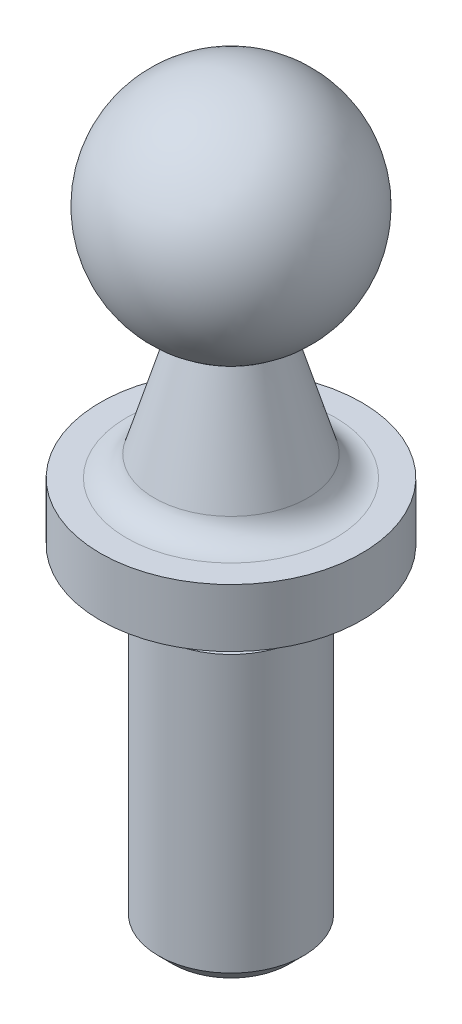
from build123d import *

# Parameters (mm, degrees)
CHANFREIN1_SIZE = 0.5
CONG_1_R        = 1


with BuildPart() as part:
    # Esquisse2 → Base-Révolution (revolve)
    with BuildSketch(Plane.XY, mode=Mode.PRIVATE) as base_r_volution_sk:
        with BuildLine():
            Line((1.5, -7.5), (2.85, -12))
            Line((2.85, -12), (4.5, -12))
            Line((4.5, -12), (4.5, -14))
            Line((4.5, -14), (2.5, -14))
            Line((2.5, -14), (2.002434927, -14))
            Line((2.002434927, -14), (2.002434927, -15.5))
            Line((2.002434927, -15.5), (2.5, -15.5))
            Line((2.5, -15.5), (2.5, -25.5))
            Line((2.5, -25.5), (0, -25.5))
            Line((0, -25.5), (0, 0))
            ThreePointArc((0, 0), (3.824264635, -3.135147073), (1.5, -7.5))
        make_face()
    revolve(base_r_volution_sk.sketch.rotate(Axis((0, 10.187617919, 0), (0, -1, 0)), 90), axis=Axis((0, 10.187617919, 0), (0, -1, 0)))  # turned: the seam where the file's is

    # Chanfrein1
    chanfrein1_edges = [part.edges().sort_by_distance(p)[0] for p in [
        (0, -25.5, -2.5),
    ]]
    chamfer(chanfrein1_edges, length=CHANFREIN1_SIZE)

    # Congé1
    cong_1_edges = [part.edges().sort_by_distance(p)[0] for p in [
        (0, -12, -2.85),
    ]]
    fillet(cong_1_edges, radius=CONG_1_R)


solid = part.part
